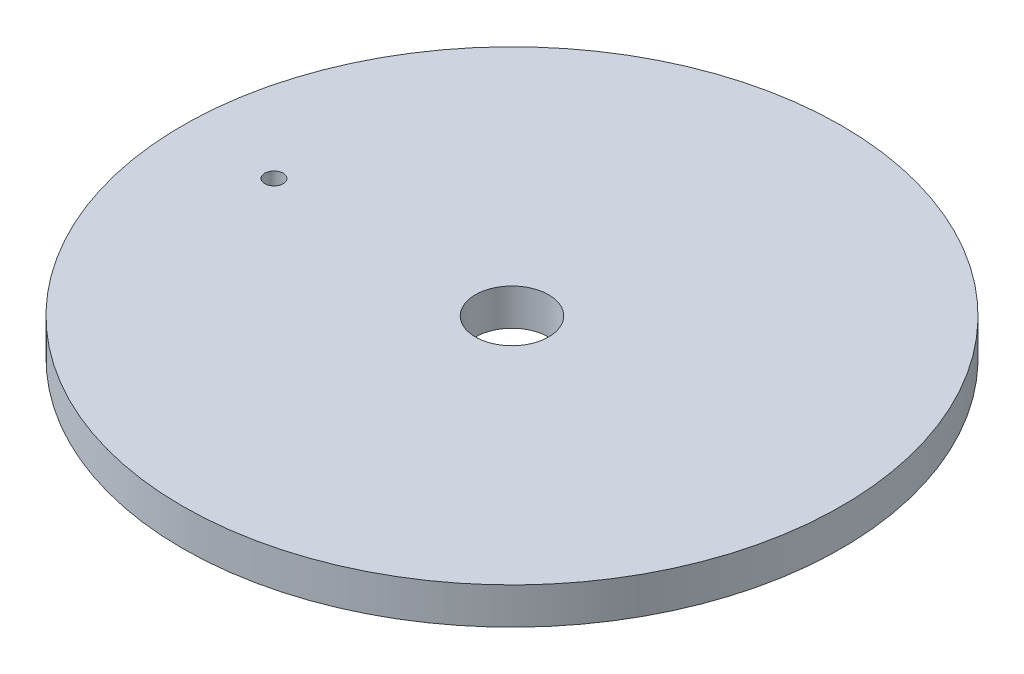
from build123d import *

# Parameters (mm, degrees)
F_1_8_0_125_DIAMETER_HOLE1_D     = 3.175
F_1_8_0_125_DIAMETER_HOLE1_DEPTH = 3.175
F_1_8_0_125_DIAMETER_HOLE1_TIP   = 0.953866233


with BuildPart() as part:
    # Sketch1 → Revolve1 (revolve)
    with BuildSketch(Plane.XY):
        Polygon((-6.35, 0), (-52.5145, 0), (-52.5145, 2.032), (-55.5625, 2.032), (-55.5625, 0), (-57.15, 0), (-57.15, 6.35), (-6.35, 6.35), align=None)
    revolve(axis=Axis((0, 0, 0), (0, 1, 0)))

    # 1/8 (0.125) Diameter Hole1
    with Locations(Plane(origin=(0, 6.35, 0), x_dir=(1, 0, 0), z_dir=(0, 1, 0))):
        with Locations((-41.275, 0)):
            Hole(F_1_8_0_125_DIAMETER_HOLE1_D / 2, depth=F_1_8_0_125_DIAMETER_HOLE1_DEPTH)
            with Locations((0, 0, -(F_1_8_0_125_DIAMETER_HOLE1_DEPTH + F_1_8_0_125_DIAMETER_HOLE1_TIP / 2))):  # 118° drill point
                Cone(0, F_1_8_0_125_DIAMETER_HOLE1_D / 2, F_1_8_0_125_DIAMETER_HOLE1_TIP, mode=Mode.SUBTRACT)


solid = part.part
